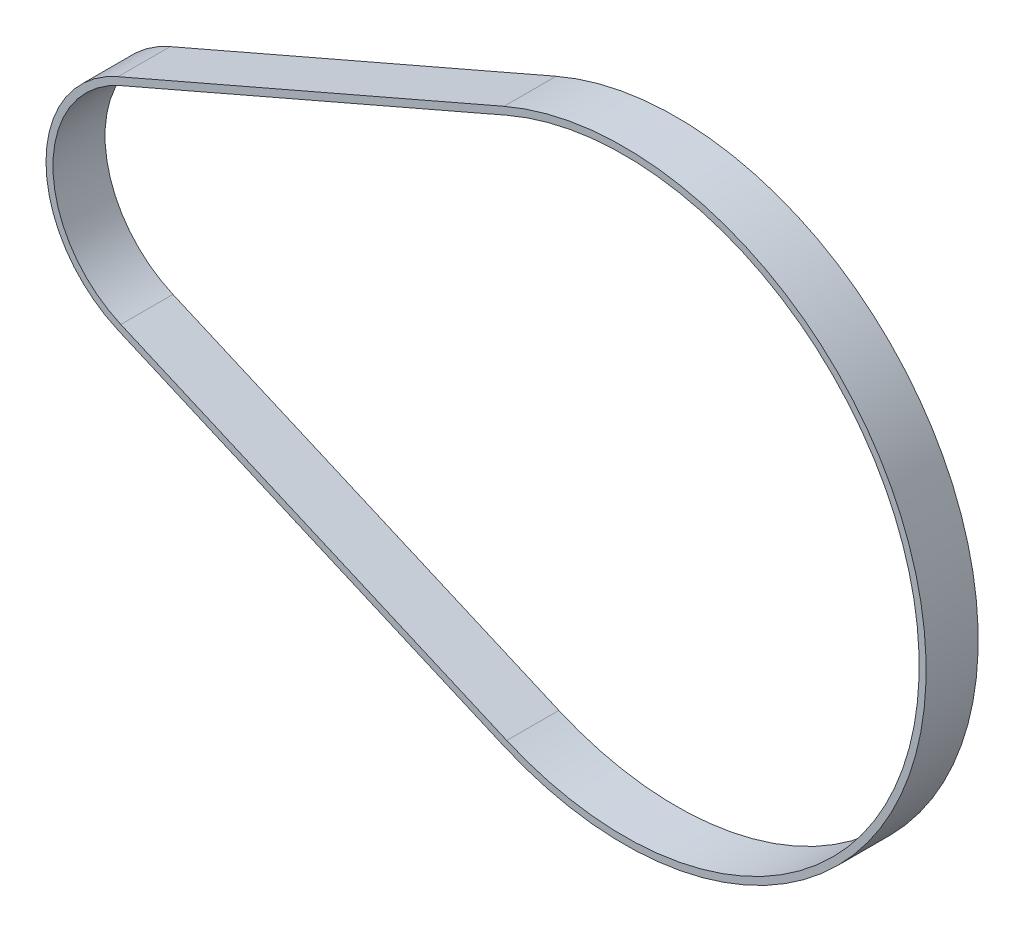
from build123d import *

# Parameters (mm, degrees)
EXTRUDE_1_DEPTH      = 3
EXTRUDE_1_DEPTH_BACK = 3


with BuildPart() as part:
    # Sketch 1 → Extrude 1 (new body, two sides)
    with BuildSketch(Plane.XY) as extrude_1_sk:
        with BuildLine():
            Line((-5.483999587, -12.650498258), (38.980167841, -31.925745039))
            ThreePointArc((38.980167841, -31.925745039), (87.6164675, 0), (38.980167841, 31.925745039))
            Line((38.980167841, 31.925745039), (-5.483999587, 12.650498258))
            ThreePointArc((-5.483999587, 12.650498258), (-13.788015, 0), (-5.483999587, -12.650498258))
        make_face()
        with BuildLine():
            Line((-5.165810227, -11.916498577), (39.298357201, -31.191745358))
            ThreePointArc((39.298357201, -31.191745358), (86.8164675, 0), (39.298357201, 31.191745358))
            Line((39.298357201, 31.191745358), (-5.165810227, 11.916498577))
            ThreePointArc((-5.165810227, 11.916498577), (-12.988015, 0), (-5.165810227, -11.916498577))
        make_face(mode=Mode.SUBTRACT)
    extrude(amount=EXTRUDE_1_DEPTH)
    extrude(extrude_1_sk.sketch, amount=-EXTRUDE_1_DEPTH_BACK)


solid = part.part
